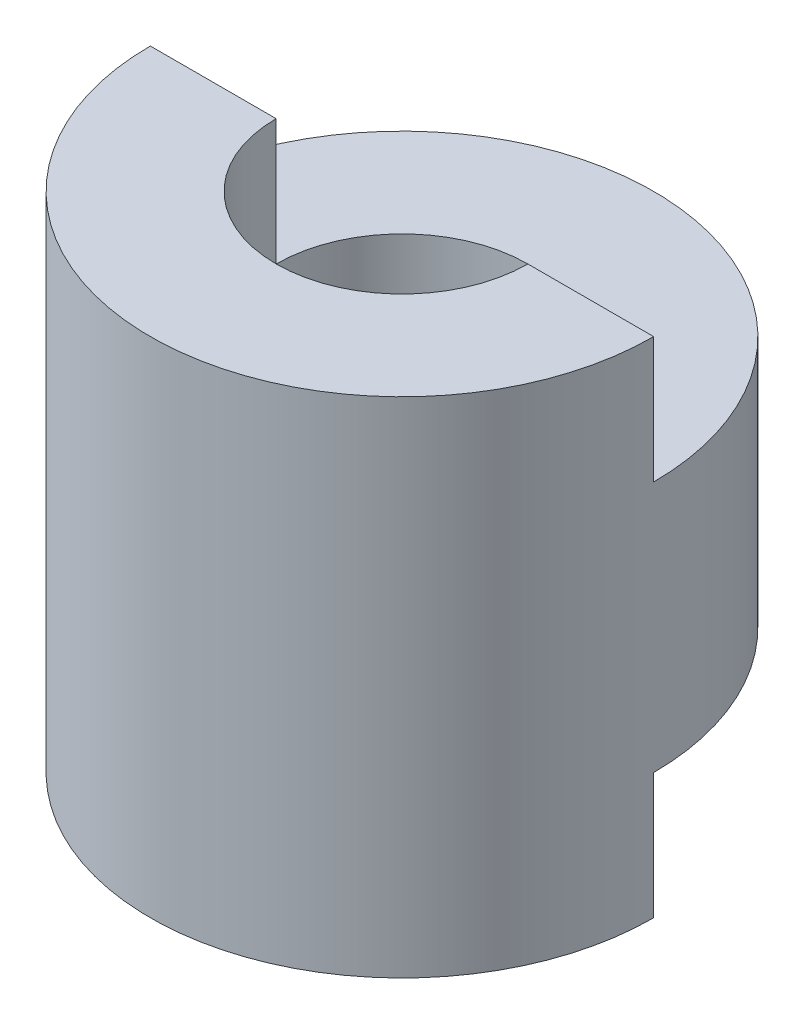
from build123d import *

# Parameters (mm, degrees)
SKETCH1_W          = 10
SKETCH1_H          = 20
SKETCH2_R          = 5
CUT_EXTRUDE1_DEPTH = 20
CUT_EXTRUDE2_DEPTH = 5
CUT_EXTRUDE3_DEPTH = 5


with BuildPart() as part:
    # Sketch1 → Revolve1 (revolve)
    with BuildSketch(Plane.XY):
        with Locations((5, 10)):
            Rectangle(SKETCH1_W, SKETCH1_H)
    revolve(axis=Axis((0, 0, 0), (0, 1, 0)))

    # Sketch2 → Cut-Extrude1 (cut)
    with BuildSketch(Plane(origin=(0, 20, 0), x_dir=(1, 0, 0), z_dir=(0, 1, 0))):
        Circle(SKETCH2_R)
    extrude(amount=-CUT_EXTRUDE1_DEPTH, mode=Mode.SUBTRACT)

    # Sketch3 → Cut-Extrude2 (cut)
    with BuildSketch(Plane(origin=(0, 20, 0), x_dir=(1, 0, 0), z_dir=(0, 1, 0))):
        with BuildLine():
            Line((-10, 0), (-5, 0))
            ThreePointArc((-5, 0), (0, 5), (5, 0))
            Line((5, 0), (10, 0))
            ThreePointArc((10, 0), (0, 10), (-10, 0))
        make_face()
    extrude(amount=-CUT_EXTRUDE2_DEPTH, mode=Mode.SUBTRACT)

    # Sketch4 → Cut-Extrude3 (cut)
    with BuildSketch(Plane.XZ):
        with BuildLine():
            Line((-10, 0), (-5, 0))
            ThreePointArc((-5, 0), (0, -5), (5, 0))
            Line((5, 0), (10, 0))
            ThreePointArc((10, 0), (0, -10), (-10, 0))
        make_face()
    extrude(amount=-CUT_EXTRUDE3_DEPTH, mode=Mode.SUBTRACT)


solid = part.part
